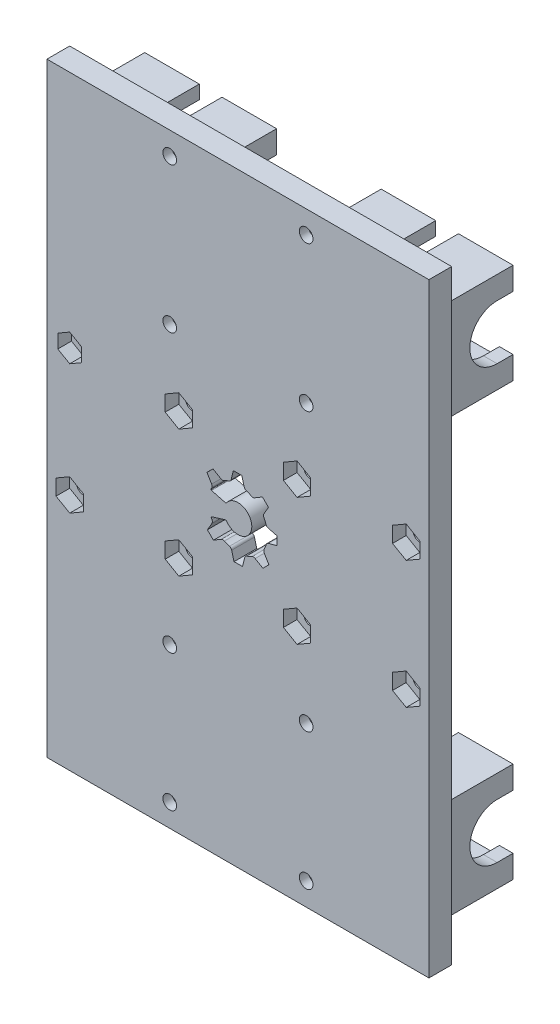
from build123d import *

# Parameters (mm, degrees)
CROQUIS1_W                = 84
CROQUIS1_H                = 133
CROQUIS1_R                = 1.5
SALIENTE_EXTRUIR1_DEPTH   = 5
CROQUIS3_W                = 29
CROQUIS3_H                = 22
SALIENTE_EXTRUIR2_DEPTH   = 15
AGUJERO_RODAMIENTOS_DEPTH = 81
CORTAR_EXTRUIR3_DEPTH     = 23
CORTAR_EXTRUIR4_DEPTH     = 23
CORTAR_EXTRUIR5_DEPTH     = 23
CORTAR_EXTRUIR6_DEPTH     = 23
CROQUIS9_W                = 5
CROQUIS9_H                = 7.5
CROQUIS9_H_2              = 3
CORTAR_EXTRUIR7_DEPTH     = 126
CORTAR_EXTRUIR11_DEPTH    = 3
CORTAR_EXTRUIR12_DEPTH    = 6
CORTAR_EXTRUIR13_DEPTH    = 3


with BuildPart() as part:
    # Croquis1 → Saliente-Extruir1 (new body)
    with BuildSketch(Plane.XY):
        with Locations((42, 66.5)):
            Rectangle(CROQUIS1_W, CROQUIS1_H)
        with Locations((57, 5)):
            Circle(CROQUIS1_R, mode=Mode.SUBTRACT)
        with Locations((27, 5)):
            Circle(CROQUIS1_R, mode=Mode.SUBTRACT)
        with Locations((27, 35)):
            Circle(CROQUIS1_R, mode=Mode.SUBTRACT)
        with Locations((57, 35)):
            Circle(CROQUIS1_R, mode=Mode.SUBTRACT)
        with Locations((57, 128)):
            Circle(CROQUIS1_R, mode=Mode.SUBTRACT)
        with Locations((27, 128)):
            Circle(CROQUIS1_R, mode=Mode.SUBTRACT)
        with Locations((27, 96)):
            Circle(CROQUIS1_R, mode=Mode.SUBTRACT)
        with Locations((57, 96)):
            Circle(CROQUIS1_R, mode=Mode.SUBTRACT)
        with Locations((5, 80.5)):
            Circle(CROQUIS1_R, mode=Mode.SUBTRACT)
        with Locations((29, 80.5)):
            Circle(CROQUIS1_R, mode=Mode.SUBTRACT)
        with Locations((29, 52.5)):
            Circle(CROQUIS1_R, mode=Mode.SUBTRACT)
        with Locations((5, 52.5)):
            Circle(CROQUIS1_R, mode=Mode.SUBTRACT)
        with Locations((79, 52.5)):
            Circle(CROQUIS1_R, mode=Mode.SUBTRACT)
        with Locations((55, 52.5)):
            Circle(CROQUIS1_R, mode=Mode.SUBTRACT)
        with Locations((55, 80.5)):
            Circle(CROQUIS1_R, mode=Mode.SUBTRACT)
        with Locations((79, 80.5)):
            Circle(CROQUIS1_R, mode=Mode.SUBTRACT)
    extrude(amount=SALIENTE_EXTRUIR1_DEPTH)

    # Croquis3 → Saliente-Extruir2 (add)
    with BuildSketch(Plane(origin=(0, 0, 0), x_dir=(-1, 0, 0), z_dir=(0, 0, -1))):
        with Locations((-68, 114)):
            Rectangle(CROQUIS3_W, CROQUIS3_H)
        with Locations((-16, 114)):
            Rectangle(CROQUIS3_W, CROQUIS3_H)
        with Locations((-68, 19)):
            Rectangle(CROQUIS3_W, CROQUIS3_H)
        with Locations((-16, 19)):
            Rectangle(CROQUIS3_W, CROQUIS3_H)
    extrude(amount=SALIENTE_EXTRUIR2_DEPTH)

    # Croquis4 → agujero rodamientos (cut)
    with BuildSketch(Plane.ZY.offset(-1.5)):
        with BuildLine():
            Line((-11.5, 25), (-15, 25))
            Line((-15, 25), (-15, 13))
            Line((-15, 13), (-11.5, 13))
            ThreePointArc((-11.5, 13), (-5.5, 19), (-11.5, 25))
        make_face()
        with BuildLine():
            Line((-11.5, 120), (-15, 120))
            Line((-15, 120), (-15, 108))
            Line((-15, 108), (-11.5, 108))
            ThreePointArc((-11.5, 108), (-5.5, 114), (-11.5, 120))
        make_face()
    extrude(amount=-AGUJERO_RODAMIENTOS_DEPTH, mode=Mode.SUBTRACT)

    # Croquis5 → Cortar-Extruir3 (cut)
    with BuildSketch(Plane.ZY.offset(-56.5)):
        with BuildLine():
            Line((-11.5, 122), (-15, 122))
            Line((-15, 122), (-15, 106))
            Line((-15, 106), (-11.5, 106))
            ThreePointArc((-11.5, 106), (-3.5, 114), (-11.5, 122))
        make_face()
    extrude(amount=-CORTAR_EXTRUIR3_DEPTH, mode=Mode.SUBTRACT)

    # Croquis6 → Cortar-Extruir4 (cut)
    with BuildSketch(Plane.ZY.offset(-4.5)):
        with BuildLine():
            Line((-11.5, 122), (-15, 122))
            Line((-15, 122), (-15, 106))
            Line((-15, 106), (-11.5, 106))
            ThreePointArc((-11.5, 106), (-3.5, 114), (-11.5, 122))
        make_face()
    extrude(amount=-CORTAR_EXTRUIR4_DEPTH, mode=Mode.SUBTRACT)

    # Croquis7 → Cortar-Extruir5 (cut)
    with BuildSketch(Plane.ZY.offset(-56.5)):
        with BuildLine():
            Line((-11.5, 27), (-15, 27))
            Line((-15, 27), (-15, 11))
            Line((-15, 11), (-11.5, 11))
            ThreePointArc((-11.5, 11), (-3.5, 19), (-11.5, 27))
        make_face()
    extrude(amount=-CORTAR_EXTRUIR5_DEPTH, mode=Mode.SUBTRACT)

    # Croquis8 → Cortar-Extruir6 (cut)
    with BuildSketch(Plane.ZY.offset(-4.5)):
        with BuildLine():
            Line((-11.5, 27), (-15, 27))
            Line((-15, 27), (-15, 11))
            Line((-15, 11), (-11.5, 11))
            ThreePointArc((-11.5, 11), (-3.5, 19), (-11.5, 27))
        make_face()
    extrude(amount=-CORTAR_EXTRUIR6_DEPTH, mode=Mode.SUBTRACT)

    # Croquis9 → Cortar-Extruir7 (cut, through all)
    with BuildSketch(Plane(origin=(0, 125, 0), x_dir=(1, 0, 0), z_dir=(0, 1, 0))):
        with Locations((16, 11.25)):
            Rectangle(CROQUIS9_W, CROQUIS9_H)
        with Locations((68, 11.25)):
            Rectangle(CROQUIS9_W, CROQUIS9_H)
        with Locations((16, 1.5)):
            Rectangle(CROQUIS9_W, CROQUIS9_H_2)
        with Locations((68, 1.5)):
            Rectangle(CROQUIS9_W, CROQUIS9_H_2)
    extrude(amount=-CORTAR_EXTRUIR7_DEPTH, mode=Mode.SUBTRACT)

    # agujeros tuercas → Cortar-Extruir11 (cut)
    with BuildSketch(Plane(origin=(0, 0, 0), x_dir=(-1, 0, 0), z_dir=(0, 0, -1))):
        Polygon((-57, 131), (-59.598076211, 129.5), (-59.598076211, 126.5), (-57, 125), (-54.401923789, 126.5), (-54.401923789, 129.5), align=None)
        Polygon((-27, 131), (-29.598076211, 129.5), (-29.598076211, 126.5), (-27, 125), (-24.401923789, 126.5), (-24.401923789, 129.5), align=None)
        Polygon((-27, 99), (-29.598076211, 97.5), (-29.598076211, 94.5), (-27, 93), (-24.401923789, 94.5), (-24.401923789, 97.5), align=None)
        Polygon((-57, 99), (-59.598076211, 97.5), (-59.598076211, 94.5), (-57, 93), (-54.401923789, 94.5), (-54.401923789, 97.5), align=None)
        Polygon((-57, 38), (-59.598076211, 36.5), (-59.598076211, 33.5), (-57, 32), (-54.401923789, 33.5), (-54.401923789, 36.5), align=None)
        Polygon((-27, 38), (-29.598076211, 36.5), (-29.598076211, 33.5), (-27, 32), (-24.401923789, 33.5), (-24.401923789, 36.5), align=None)
        Polygon((-57, 8), (-59.598076211, 6.5), (-59.598076211, 3.5), (-57, 2), (-54.401923789, 3.5), (-54.401923789, 6.5), align=None)
        Polygon((-27, 8), (-29.598076211, 6.5), (-29.598076211, 3.5), (-27, 2), (-24.401923789, 3.5), (-24.401923789, 6.5), align=None)
    extrude(amount=-CORTAR_EXTRUIR11_DEPTH, mode=Mode.SUBTRACT)

    # Croquis10 → Cortar-Extruir12 (cut, through all)
    with BuildSketch(Plane.XY):
        with BuildLine():
            Line((35.188139939, 71.884668839), (36.501537669, 73.220342848))
            Line((36.501537669, 73.220342848), (38.224863288, 72.21739732))
            ThreePointArc((38.224863288, 72.21739732), (38.575067996, 72.119782903), (38.928320792, 72.205715279))
            ThreePointArc((38.928320792, 72.205715279), (39.469957789, 72.465675688), (40.033343063, 72.674355067))
            ThreePointArc((40.033343063, 72.674355067), (40.340671144, 72.868574947), (40.513928995, 73.18818976))
            Line((40.513928995, 73.18818976), (40.990823409, 75.124248292))
            Line((40.990823409, 75.124248292), (42.864, 75.14))
            Line((42.864, 75.14), (43.373385647, 73.212235184))
            ThreePointArc((43.373385647, 73.212235184), (43.551993955, 72.895579245), (43.862544768, 72.706555163))
            ThreePointArc((43.862544768, 72.706555163), (44.429359729, 72.507379737), (44.975291881, 72.256564794))
            ThreePointArc((44.975291881, 72.256564794), (45.329939845, 72.176585218), (45.678453448, 72.280075218))
            Line((45.678453448, 72.280075218), (47.384668839, 73.311860061))
            Line((47.384668839, 73.311860061), (48.720342848, 71.998462331))
            Line((48.720342848, 71.998462331), (47.71739732, 70.275136712))
            ThreePointArc((47.71739732, 70.275136712), (47.619782903, 69.924932004), (47.705715279, 69.571679208))
            ThreePointArc((47.705715279, 69.571679208), (47.965675688, 69.030042211), (48.174355067, 68.466656937))
            ThreePointArc((48.174355067, 68.466656937), (48.368574947, 68.159328856), (48.68818976, 67.986071005))
            Line((48.68818976, 67.986071005), (50.624248292, 67.509176591))
            Line((50.624248292, 67.509176591), (50.64, 65.636))
            Line((50.64, 65.636), (48.712235184, 65.126614353))
            ThreePointArc((48.712235184, 65.126614353), (48.395579245, 64.948006045), (48.206555163, 64.637455232))
            ThreePointArc((48.206555163, 64.637455232), (48.007379737, 64.070640271), (47.756564794, 63.524708119))
            ThreePointArc((47.756564794, 63.524708119), (47.676585218, 63.170060155), (47.780075218, 62.821546552))
            Line((47.780075218, 62.821546552), (48.811860061, 61.115331161))
            Line((48.811860061, 61.115331161), (47.498462331, 59.779657152))
            Line((47.498462331, 59.779657152), (45.775136712, 60.78260268))
            ThreePointArc((45.775136712, 60.78260268), (45.424932004, 60.880217097), (45.071679208, 60.794284721))
            ThreePointArc((45.071679208, 60.794284721), (44.530042211, 60.534324312), (43.966656937, 60.325644933))
            ThreePointArc((43.966656937, 60.325644933), (43.659328856, 60.131425053), (43.486071005, 59.81181024))
            Line((43.486071005, 59.81181024), (43.009176591, 57.875751708))
            Line((43.009176591, 57.875751708), (41.136, 57.86))
            Line((41.136, 57.86), (40.626614353, 59.787764816))
            ThreePointArc((40.626614353, 59.787764816), (40.448006045, 60.104420755), (40.137455232, 60.293444837))
            ThreePointArc((40.137455232, 60.293444837), (39.570640271, 60.492620263), (39.024708119, 60.743435206))
            ThreePointArc((39.024708119, 60.743435206), (38.670060155, 60.823414782), (38.321546552, 60.719924782))
            Line((38.321546552, 60.719924782), (36.615331161, 59.688139939))
            Line((36.615331161, 59.688139939), (35.279657152, 61.001537669))
            Line((35.279657152, 61.001537669), (36.28260268, 62.724863288))
            ThreePointArc((36.28260268, 62.724863288), (36.380217097, 63.075067996), (36.294284721, 63.428320792))
            ThreePointArc((36.294284721, 63.428320792), (36.208247472, 63.593799276), (36.127008205, 63.761685303))
            ThreePointArc((36.127008205, 63.761685303), (36.125953752, 63.873547873), (36.209575503, 63.947856347))
            Line((36.209575503, 63.947856347), (39.384042323, 64.928554615))
            ThreePointArc((39.384042323, 64.928554615), (45.05159058, 66.478318352), (39.406635637, 68.108457784))
            Line((39.406635637, 68.108457784), (36.170602247, 68.95232588))
            ThreePointArc((36.170602247, 68.95232588), (36.082937198, 69.024508031), (36.08129489, 69.138054174))
            ThreePointArc((36.08129489, 69.138054174), (36.159930296, 69.30784363), (36.243435206, 69.475291881))
            ThreePointArc((36.243435206, 69.475291881), (36.323414782, 69.829939845), (36.219924782, 70.178453448))
            Line((36.219924782, 70.178453448), (35.188139939, 71.884668839))
        make_face()
    extrude(amount=CORTAR_EXTRUIR12_DEPTH, mode=Mode.SUBTRACT)

    # Croquis11 → Cortar-Extruir13 (cut)
    with BuildSketch(Plane.XY.offset(5)):
        Polygon((5, 83.517994067), (2.38634047, 82.008997033), (2.38634047, 78.991002967), (5, 77.482005933), (7.61365953, 78.991002967), (7.61365953, 82.008997033), align=None)
        Polygon((29, 83.964101615), (26, 82.232050808), (26, 78.767949192), (29, 77.035898385), (32, 78.767949192), (32, 82.232050808), align=None)
        Polygon((55, 83.964101615), (52, 82.232050808), (52, 78.767949192), (55, 77.035898385), (58, 78.767949192), (58, 82.232050808), align=None)
        Polygon((79, 83.964101615), (76, 82.232050808), (76, 78.767949192), (79, 77.035898385), (82, 78.767949192), (82, 82.232050808), align=None)
        Polygon((55, 55.964101615), (52, 54.232050808), (52, 50.767949192), (55, 49.035898385), (58, 50.767949192), (58, 54.232050808), align=None)
        Polygon((29, 55.964101615), (26, 54.232050808), (26, 50.767949192), (29, 49.035898385), (32, 50.767949192), (32, 54.232050808), align=None)
        Polygon((5, 55.964101615), (2, 54.232050808), (2, 50.767949192), (5, 49.035898385), (8, 50.767949192), (8, 54.232050808), align=None)
        Polygon((79, 55.964101615), (76, 54.232050808), (76, 50.767949192), (79, 49.035898385), (82, 50.767949192), (82, 54.232050808), align=None)
    extrude(amount=-CORTAR_EXTRUIR13_DEPTH, mode=Mode.SUBTRACT)


solid = part.part
